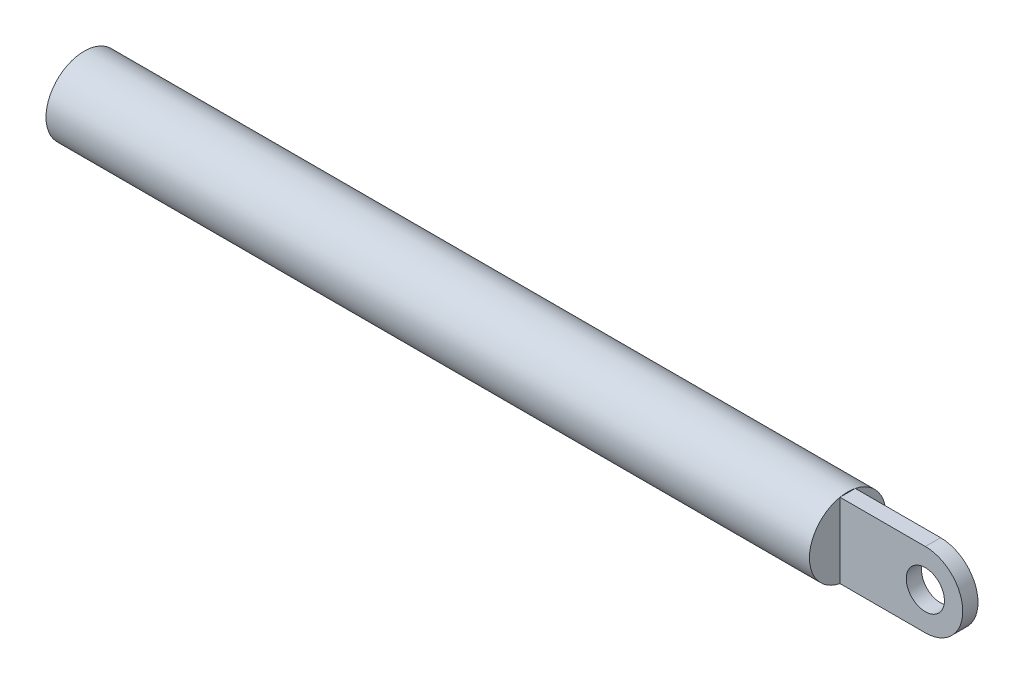
from build123d import *

# Parameters (mm, degrees)
SKETCH1_W           = 100
SKETCH1_H           = 5
SKETCH4_W           = 2
SKETCH4_H           = 9.797958971
BOSS_EXTRUDE4_DEPTH = 20
CUT_EXTRUDE5_DEPTH  = 2
SKETCH11_R          = 2.5
CUT_EXTRUDE6_DEPTH  = 2


with BuildPart() as part:
    # Sketch1 → Revolve1 (revolve)
    with BuildSketch(Plane.XY):
        with Locations((-23.848684211, 16.332236842)):
            Rectangle(SKETCH1_W, SKETCH1_H)
    revolve(axis=Axis((-73.848684211, 13.832236842, 0), (1, 0, 0)))

    # Sketch4 → Boss-Extrude4 (add)
    with BuildSketch(Plane(origin=(26.151315789, 0, 0), x_dir=(0, 0, -1), z_dir=(1, 0, 0))):
        with Locations((0, 13.832236843)):
            Rectangle(SKETCH4_W, SKETCH4_H)
    extrude(amount=BOSS_EXTRUDE4_DEPTH)

    # Sketch10 → Cut-Extrude5 (cut)
    with BuildSketch(Plane.XY.offset(1)):
        with BuildLine():
            Line((37.327139049, 18.731216328), (46.151315789, 18.731216328))
            Line((46.151315789, 18.731216328), (46.151315789, 8.933257357))
            Line((46.151315789, 8.933257357), (37.327139049, 8.933257357))
            ThreePointArc((37.327139049, 8.933257357), (42.226118535, 13.832236842), (37.327139049, 18.731216328))
        make_face()
    extrude(amount=-CUT_EXTRUDE5_DEPTH, mode=Mode.SUBTRACT)

    # Sketch11 → Cut-Extrude6 (cut)
    with BuildSketch(Plane.XY.offset(1)):
        with Locations((37.327139049, 13.832236842)):
            Circle(SKETCH11_R)
    extrude(amount=-CUT_EXTRUDE6_DEPTH, mode=Mode.SUBTRACT)


solid = part.part
